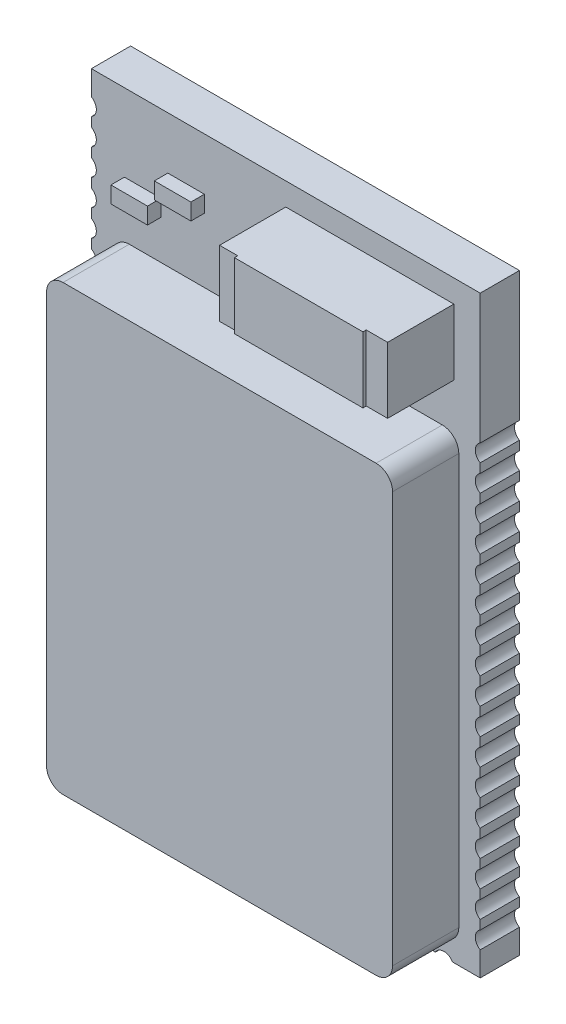
from build123d import *

# Parameters (mm, degrees)
SKETCH1_W               = 11.8
SKETCH1_H               = 18
BOSS_EXTRUDE1_DEPTH     = 1.19
SKETCH2_W               = 10.5
SKETCH2_H               = 13.46
BOSS_EXTRUDE2_DEPTH     = 3.2
FILLET11_R              = 0.5
FILLET12_R              = 0.5
FILLET13_R              = 0.5
FILLET14_R              = 0.5
SKETCH9_R               = 0.3
CUT_EXTRUDE5_DEPTH      = 3.2
SKETCH14_W              = 5.1
SKETCH14_H              = 2
BOSS_EXTRUDE3_DEPTH     = 3.2
SKETCH15_W              = 3.9
SKETCH15_H              = 2
BOSS_EXTRUDE4_DEPTH     = 3.3
SKETCH16_R              = 0.3
CUT_EXTRUDE6_DEPTH      = 4.3
CUT_EXTRUDE6_DEPTH_BACK = 1
SKETCH17_R              = 0.3
CUT_EXTRUDE9_DEPTH      = 4.3
CUT_EXTRUDE9_DEPTH_BACK = 3.2
SKETCH19_W              = 1.11
SKETCH19_H              = 0.5
BOSS_EXTRUDE6_DEPTH     = 1.6
SKETCH20_W              = 1.11
SKETCH20_H              = 0.5
BOSS_EXTRUDE7_DEPTH     = 1.6


with BuildPart() as part:
    # Sketch1 → Boss-Extrude1 (new body)
    with BuildSketch(Plane.XY):
        with Locations((5.9, 9)):
            Rectangle(SKETCH1_W, SKETCH1_H)
    extrude(amount=BOSS_EXTRUDE1_DEPTH)

    # Sketch2 → Boss-Extrude2 (add)
    with BuildSketch(Plane.XY):
        with Locations((5.9, 7.23)):
            Rectangle(SKETCH2_W, SKETCH2_H)
    extrude(amount=BOSS_EXTRUDE2_DEPTH)

    # Fillet11
    fillet11_edges = [part.edges().sort_by_distance(p)[0] for p in [
        (0.65, 13.96, 2.195),
    ]]
    fillet(fillet11_edges, radius=FILLET11_R)

    # Fillet12
    fillet12_edges = [part.edges().sort_by_distance(p)[0] for p in [
        (0.65, 0.5, 2.195),
    ]]
    fillet(fillet12_edges, radius=FILLET12_R)

    # Fillet13
    fillet13_edges = [part.edges().sort_by_distance(p)[0] for p in [
        (11.15, 0.5, 2.195),
    ]]
    fillet(fillet13_edges, radius=FILLET13_R)

    # Fillet14
    fillet14_edges = [part.edges().sort_by_distance(p)[0] for p in [
        (11.15, 13.96, 2.195),
    ]]
    fillet(fillet14_edges, radius=FILLET14_R)

    # Sketch9 → Cut-Extrude5 (cut)
    with BuildSketch(Plane.XY):
        with Locations((1.1, -0.15)):
            Circle(SKETCH9_R)
        with Locations((1.9, -0.15)):
            Circle(SKETCH9_R)
        with Locations((2.7, -0.15)):
            Circle(SKETCH9_R)
        with Locations((3.5, -0.15)):
            Circle(SKETCH9_R)
        with Locations((4.3, -0.15)):
            Circle(SKETCH9_R)
        with Locations((5.1, -0.15)):
            Circle(SKETCH9_R)
        with Locations((5.9, -0.15)):
            Circle(SKETCH9_R)
        with Locations((6.7, -0.15)):
            Circle(SKETCH9_R)
        with Locations((7.5, -0.15)):
            Circle(SKETCH9_R)
        with Locations((8.3, -0.15)):
            Circle(SKETCH9_R)
        with Locations((9.1, -0.15)):
            Circle(SKETCH9_R)
        with Locations((9.9, -0.15)):
            Circle(SKETCH9_R)
        with Locations((10.7, -0.15)):
            Circle(SKETCH9_R)
    extrude(amount=CUT_EXTRUDE5_DEPTH, mode=Mode.SUBTRACT)

    # Sketch14 → Boss-Extrude3 (add)
    with BuildSketch(Plane.XY):
        with Locations((8.45, 16.312688451)):
            Rectangle(SKETCH14_W, SKETCH14_H)
    extrude(amount=BOSS_EXTRUDE3_DEPTH)

    # Sketch15 → Boss-Extrude4 (add)
    with BuildSketch(Plane.XY):
        with Locations((8.401012654, 16.312688451)):
            Rectangle(SKETCH15_W, SKETCH15_H)
    extrude(amount=BOSS_EXTRUDE4_DEPTH)

    # Sketch16 → Cut-Extrude6 (cut, two sides)
    with BuildSketch(Plane.XY) as cut_extrude6_sk:
        with Locations((-0.15, 1)):
            Circle(SKETCH16_R)
        with Locations((-0.15, 1.8)):
            Circle(SKETCH16_R)
        with Locations((-0.15, 2.6)):
            Circle(SKETCH16_R)
        with Locations((-0.15, 3.4)):
            Circle(SKETCH16_R)
        with Locations((-0.15, 4.2)):
            Circle(SKETCH16_R)
        with Locations((-0.15, 5)):
            Circle(SKETCH16_R)
        with Locations((-0.15, 5.8)):
            Circle(SKETCH16_R)
        with Locations((-0.15, 6.6)):
            Circle(SKETCH16_R)
        with Locations((-0.15, 7.4)):
            Circle(SKETCH16_R)
        with Locations((-0.15, 8.2)):
            Circle(SKETCH16_R)
        with Locations((-0.15, 9)):
            Circle(SKETCH16_R)
        with Locations((-0.15, 9.8)):
            Circle(SKETCH16_R)
        with Locations((-0.15, 10.6)):
            Circle(SKETCH16_R)
        with Locations((-0.15, 11.4)):
            Circle(SKETCH16_R)
        with Locations((-0.15, 12.2)):
            Circle(SKETCH16_R)
        with Locations((-0.15, 13)):
            Circle(SKETCH16_R)
        with Locations((-0.15, 13.8)):
            Circle(SKETCH16_R)
        with Locations((-0.15, 14.6)):
            Circle(SKETCH16_R)
        with Locations((-0.15, 15.4)):
            Circle(SKETCH16_R)
        with Locations((-0.15, 16.2)):
            Circle(SKETCH16_R)
        with Locations((-0.15, 17)):
            Circle(SKETCH16_R)
    extrude(amount=CUT_EXTRUDE6_DEPTH, mode=Mode.SUBTRACT)
    extrude(cut_extrude6_sk.sketch, amount=-CUT_EXTRUDE6_DEPTH_BACK, mode=Mode.SUBTRACT)

    # Sketch17 → Cut-Extrude9 (cut, two sides)
    with BuildSketch(Plane.XY) as cut_extrude9_sk:
        with Locations((11.95, 1)):
            Circle(SKETCH17_R)
        with Locations((11.95, 1.8)):
            Circle(SKETCH17_R)
        with Locations((11.95, 2.6)):
            Circle(SKETCH17_R)
        with Locations((11.95, 3.4)):
            Circle(SKETCH17_R)
        with Locations((11.95, 4.2)):
            Circle(SKETCH17_R)
        with Locations((11.95, 5)):
            Circle(SKETCH17_R)
        with Locations((11.95, 5.8)):
            Circle(SKETCH17_R)
        with Locations((11.95, 6.6)):
            Circle(SKETCH17_R)
        with Locations((11.95, 7.4)):
            Circle(SKETCH17_R)
        with Locations((11.95, 8.2)):
            Circle(SKETCH17_R)
        with Locations((11.95, 9)):
            Circle(SKETCH17_R)
        with Locations((11.95, 9.8)):
            Circle(SKETCH17_R)
        with Locations((11.95, 10.6)):
            Circle(SKETCH17_R)
        with Locations((11.95, 11.4)):
            Circle(SKETCH17_R)
        with Locations((11.95, 12.2)):
            Circle(SKETCH17_R)
        with Locations((11.95, 13)):
            Circle(SKETCH17_R)
        with Locations((11.95, 13.8)):
            Circle(SKETCH17_R)
    extrude(amount=CUT_EXTRUDE9_DEPTH, mode=Mode.SUBTRACT)
    extrude(cut_extrude9_sk.sketch, amount=-CUT_EXTRUDE9_DEPTH_BACK, mode=Mode.SUBTRACT)

    # Sketch19 → Boss-Extrude6 (add)
    with BuildSketch(Plane.XY):
        with Locations((2.875, 16.16471376)):
            Rectangle(SKETCH19_W, SKETCH19_H)
    extrude(amount=BOSS_EXTRUDE6_DEPTH)

    # Sketch20 → Boss-Extrude7 (add)
    with BuildSketch(Plane.XY):
        with Locations((1.55773637, 15.39942892)):
            Rectangle(SKETCH20_W, SKETCH20_H)
    extrude(amount=BOSS_EXTRUDE7_DEPTH)


solid = part.part
